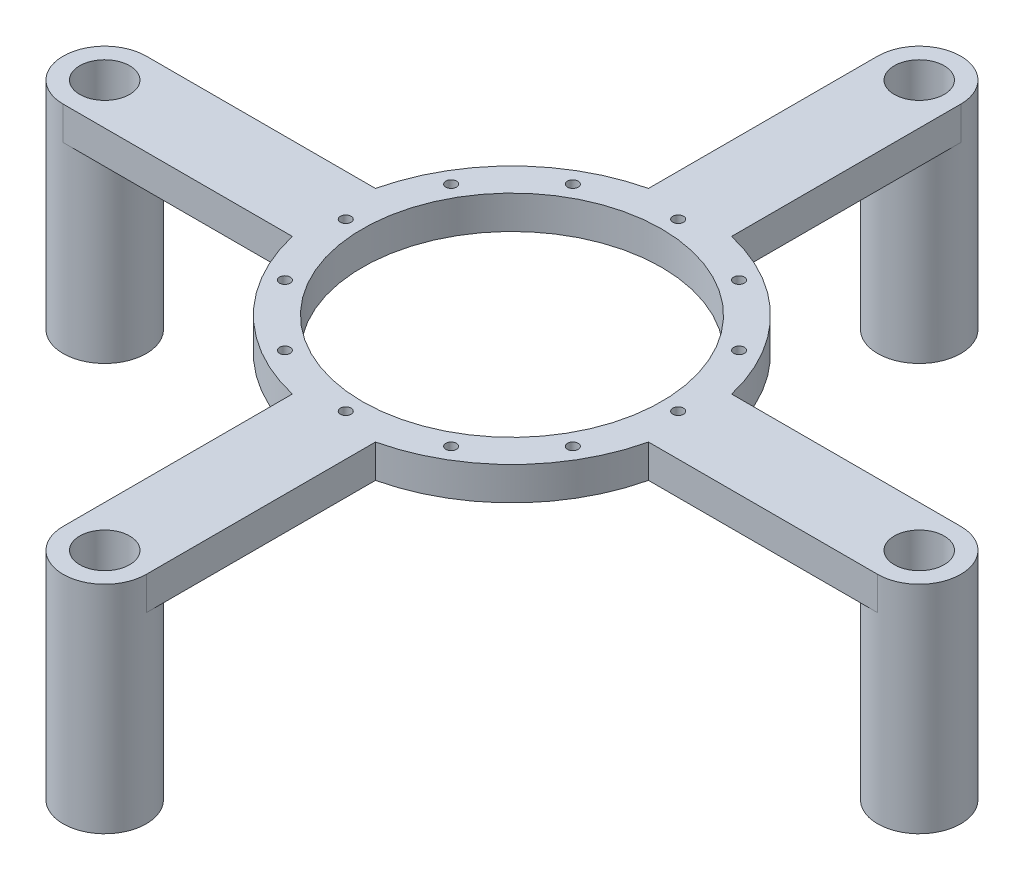
from build123d import *

# Parameters (mm, degrees)
SKETCH1_R           = 7.5
SKETCH1_R_2         = 1.6
SKETCH1_R_3         = 45
BOSS_EXTRUDE1_DEPTH = 65
SKETCH1_3_R         = 7.5
SKETCH1_3_R_2       = 1.6
BOSS_EXTRUDE2_DEPTH = 3.2
SKETCH1_5_R         = 1.6
SKETCH1_5_R_2       = 45
CUT_EXTRUDE2_DEPTH  = 55


with BuildPart() as part:
    # Sketch1 → Boss-Extrude1 (new body)
    with BuildSketch(Plane(origin=(0, 0, 0), x_dir=(1, 0, 0), z_dir=(0, 1, 0))):
        with BuildLine():
            Line((53.560713214, -12.5), (122.5, -12.5))
            ThreePointArc((122.5, -12.5), (135, 0), (122.5, 12.5))
            Line((122.5, 12.5), (53.560713214, 12.5))
            ThreePointArc((53.560713214, 12.5), (38.890872965, 38.890872965), (12.5, 53.560713214))
            Line((12.5, 53.560713214), (12.5, 122.5))
            ThreePointArc((12.5, 122.5), (0, 135), (-12.5, 122.5))
            Line((-12.5, 122.5), (-12.5, 53.560713214))
            ThreePointArc((-12.5, 53.560713214), (-38.890872965, 38.890872965), (-53.560713214, 12.5))
            Line((-53.560713214, 12.5), (-122.5, 12.5))
            ThreePointArc((-122.5, 12.5), (-135, 0), (-122.5, -12.5))
            Line((-122.5, -12.5), (-53.560713214, -12.5))
            ThreePointArc((-53.560713214, -12.5), (-38.890872965, -38.890872965), (-12.5, -53.560713214))
            Line((-12.5, -53.560713214), (-12.5, -122.5))
            ThreePointArc((-12.5, -122.5), (0, -135), (12.5, -122.5))
            Line((12.5, -122.5), (12.5, -53.560713214))
            ThreePointArc((12.5, -53.560713214), (38.890872965, -38.890872965), (53.560713214, -12.5))
        make_face()
        with Locations((122.5, 0)):
            Circle(SKETCH1_R, mode=Mode.SUBTRACT)
        with Locations((25, 43.301270189)):
            Circle(SKETCH1_R_2, mode=Mode.SUBTRACT)
        with Locations((0, 50)):
            Circle(SKETCH1_R_2, mode=Mode.SUBTRACT)
        with Locations((-25, -43.301270189)):
            Circle(SKETCH1_R_2, mode=Mode.SUBTRACT)
        with Locations((0, -50)):
            Circle(SKETCH1_R_2, mode=Mode.SUBTRACT)
        with Locations((-43.301270189, -25)):
            Circle(SKETCH1_R_2, mode=Mode.SUBTRACT)
        with Locations((25, -43.301270189)):
            Circle(SKETCH1_R_2, mode=Mode.SUBTRACT)
        with Locations((43.301270189, -25)):
            Circle(SKETCH1_R_2, mode=Mode.SUBTRACT)
        with Locations((50, 0)):
            Circle(SKETCH1_R_2, mode=Mode.SUBTRACT)
        with Locations((-50, 0)):
            Circle(SKETCH1_R_2, mode=Mode.SUBTRACT)
        with Locations((-43.301270189, 25)):
            Circle(SKETCH1_R_2, mode=Mode.SUBTRACT)
        Circle(SKETCH1_R_3, mode=Mode.SUBTRACT)
        with Locations((-25, 43.301270189)):
            Circle(SKETCH1_R_2, mode=Mode.SUBTRACT)
        with Locations((43.301270189, 25)):
            Circle(SKETCH1_R_2, mode=Mode.SUBTRACT)
        with Locations((0, 122.5)):
            Circle(SKETCH1_R, mode=Mode.SUBTRACT)
        with Locations((0, -122.5)):
            Circle(SKETCH1_R, mode=Mode.SUBTRACT)
        with Locations((-122.5, 0)):
            Circle(SKETCH1_R, mode=Mode.SUBTRACT)
    extrude(amount=BOSS_EXTRUDE1_DEPTH)

    # Sketch1_3 → Boss-Extrude2 (add)
    with BuildSketch(Plane(origin=(0, 0, 0), x_dir=(1, 0, 0), z_dir=(0, 1, 0))):
        with Locations((0, -122.5)):
            Circle(SKETCH1_3_R)
        with Locations((0, -122.5)):
            Circle(SKETCH1_3_R_2, mode=Mode.SUBTRACT)
        with Locations((122.5, 0)):
            Circle(SKETCH1_3_R)
        with Locations((122.5, 0)):
            Circle(SKETCH1_3_R_2, mode=Mode.SUBTRACT)
        with Locations((0, 122.5)):
            Circle(SKETCH1_3_R)
        with Locations((0, 122.5)):
            Circle(SKETCH1_3_R_2, mode=Mode.SUBTRACT)
        with Locations((-122.5, 0)):
            Circle(SKETCH1_3_R)
        with Locations((-122.5, 0)):
            Circle(SKETCH1_3_R_2, mode=Mode.SUBTRACT)
    extrude(amount=BOSS_EXTRUDE2_DEPTH)

    # Sketch1_5 → Cut-Extrude2 (cut)
    with BuildSketch(Plane(origin=(0, 0, 0), x_dir=(1, 0, 0), z_dir=(0, 1, 0))):
        with BuildLine():
            ThreePointArc((122.5, -12.5), (110, 0), (122.5, 12.5))
            Line((122.5, 12.5), (53.560713214, 12.5))
            ThreePointArc((53.560713214, 12.5), (38.890872965, 38.890872965), (12.5, 53.560713214))
            Line((12.5, 53.560713214), (12.5, 122.5))
            ThreePointArc((12.5, 122.5), (0, 110), (-12.5, 122.5))
            Line((-12.5, 122.5), (-12.5, 53.560713214))
            ThreePointArc((-12.5, 53.560713214), (-38.890872965, 38.890872965), (-53.560713214, 12.5))
            Line((-53.560713214, 12.5), (-122.5, 12.5))
            ThreePointArc((-122.5, 12.5), (-110, 0), (-122.5, -12.5))
            Line((-122.5, -12.5), (-53.560713214, -12.5))
            ThreePointArc((-53.560713214, -12.5), (-38.890872965, -38.890872965), (-12.5, -53.560713214))
            Line((-12.5, -53.560713214), (-12.5, -122.5))
            ThreePointArc((-12.5, -122.5), (0, -110), (12.5, -122.5))
            Line((12.5, -122.5), (12.5, -53.560713214))
            ThreePointArc((12.5, -53.560713214), (38.890872965, -38.890872965), (53.560713214, -12.5))
            Line((53.560713214, -12.5), (122.5, -12.5))
        make_face()
        with Locations((0, 50)):
            Circle(SKETCH1_5_R, mode=Mode.SUBTRACT)
        with Locations((25, 43.301270189)):
            Circle(SKETCH1_5_R, mode=Mode.SUBTRACT)
        with Locations((-25, -43.301270189)):
            Circle(SKETCH1_5_R, mode=Mode.SUBTRACT)
        with Locations((0, -50)):
            Circle(SKETCH1_5_R, mode=Mode.SUBTRACT)
        with Locations((-43.301270189, -25)):
            Circle(SKETCH1_5_R, mode=Mode.SUBTRACT)
        with Locations((25, -43.301270189)):
            Circle(SKETCH1_5_R, mode=Mode.SUBTRACT)
        with Locations((43.301270189, -25)):
            Circle(SKETCH1_5_R, mode=Mode.SUBTRACT)
        with Locations((50, 0)):
            Circle(SKETCH1_5_R, mode=Mode.SUBTRACT)
        with Locations((-50, 0)):
            Circle(SKETCH1_5_R, mode=Mode.SUBTRACT)
        with Locations((-43.301270189, 25)):
            Circle(SKETCH1_5_R, mode=Mode.SUBTRACT)
        Circle(SKETCH1_5_R_2, mode=Mode.SUBTRACT)
        with Locations((-25, 43.301270189)):
            Circle(SKETCH1_5_R, mode=Mode.SUBTRACT)
        with Locations((43.301270189, 25)):
            Circle(SKETCH1_5_R, mode=Mode.SUBTRACT)
    extrude(amount=CUT_EXTRUDE2_DEPTH, mode=Mode.SUBTRACT)


solid = part.part
